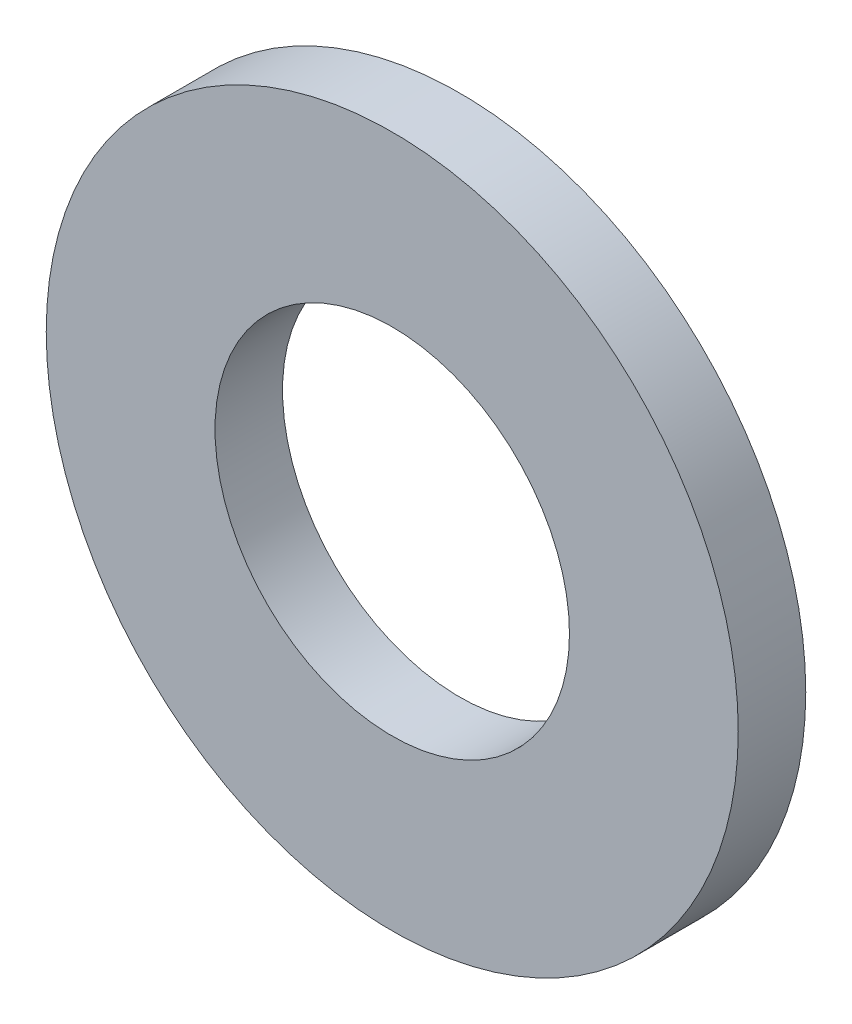
from build123d import *

# Parameters (mm, degrees)
SKETCH2_R           = 6.15
SKETCH2_R_2         = 3.15
BOSS_EXTRUDE1_DEPTH = 1.2


with BuildPart() as part:
    # Sketch2 → Boss-Extrude1 (new body)
    with BuildSketch(Plane.XY):
        Circle(SKETCH2_R)
        Circle(SKETCH2_R_2, mode=Mode.SUBTRACT)
    extrude(amount=BOSS_EXTRUDE1_DEPTH)


solid = part.part
